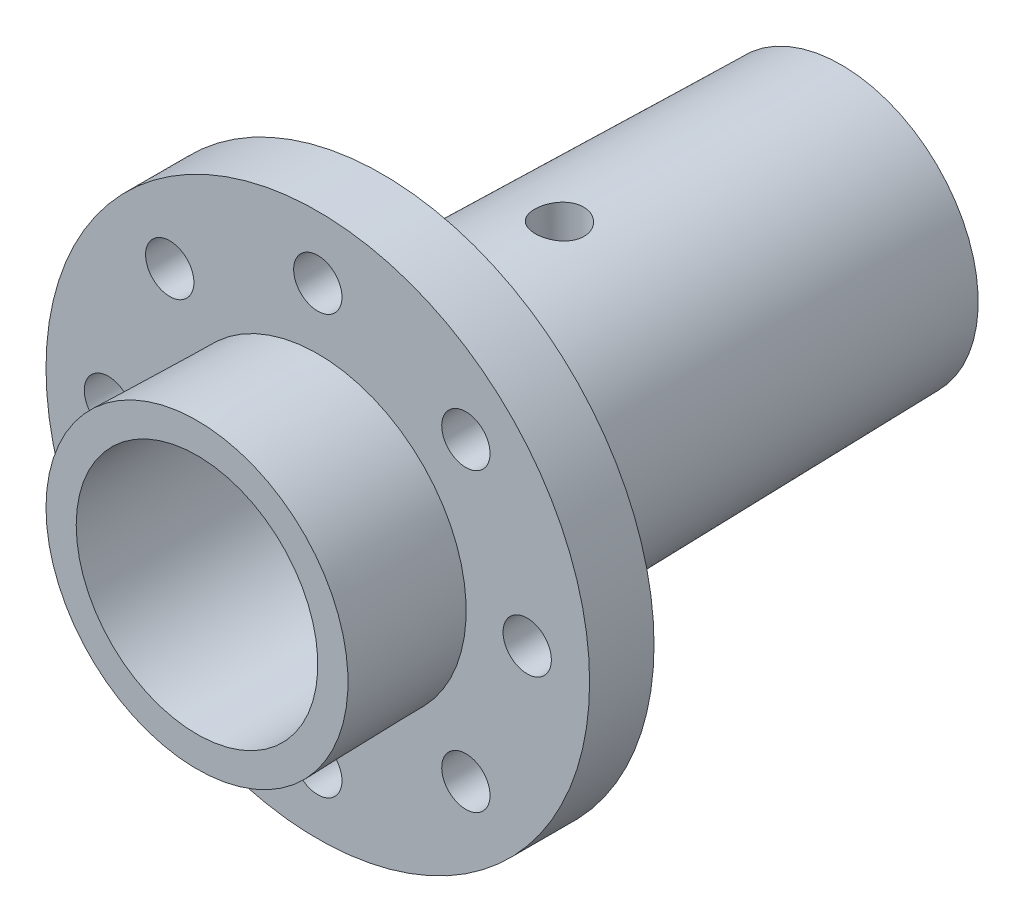
from build123d import *

# Parameters (mm, degrees)
SCHIZZO5_W                  = 15
SCHIZZO5_H                  = 30
SCHIZZO7_R                  = 3
TAGLIO_ESTRUSIONE1_DEPTH    = 24
RIPETIZIONECIRCOLARE1_COUNT = 8
SCHIZZO8_R                  = 3
TAGLIO_ESTRUSIONE2_DEPTH    = 34.75


with BuildPart() as part:
    # Schizzo3 → Rivoluzione2 (revolve)
    with BuildSketch(Plane(origin=(0, 0, 0), x_dir=(1, 0, 0), z_dir=(0, 1, 0))):
        Polygon((-17, 40), (-12, 40), (-12, -40), (-18.75, -40), (-18.421875, -25), (-33.75, -25), (-33.75, -17), (-18.246875, -17), align=None)
    revolve(axis=Axis((0, 0, -65.081098712), (0, 0, 1)))

    # Schizzo5 → Taglia-Rivoluzione1 (revolve, cut)
    with BuildSketch(Plane(origin=(0, 0, 0), x_dir=(1, 0, 0), z_dir=(0, 1, 0))):
        with Locations((-7.5, -25)):
            Rectangle(SCHIZZO5_W, SCHIZZO5_H)
    revolve(axis=Axis((0, 0, -67.558392607), (0, 0, 1)), mode=Mode.SUBTRACT)

    # Schizzo7 → Taglio-Estrusione1 (cut, through all)
    with BuildSketch(Plane(origin=(0, 0, 17), x_dir=(-1, 0, 0), z_dir=(0, 0, -1))):
        with Locations((0, -26)):
            Circle(SCHIZZO7_R)
    taglio_estrusione1 = extrude(amount=-TAGLIO_ESTRUSIONE1_DEPTH, mode=Mode.SUBTRACT)

    # RipetizioneCircolare1: Taglio-Estrusione1 ×8 about axis
    ripetizionecircolare1_axis = Axis((0, 0, 0), (0, 0, 1))
    for i in range(1, RIPETIZIONECIRCOLARE1_COUNT):
        add(taglio_estrusione1.rotate(ripetizionecircolare1_axis, i * 360 / RIPETIZIONECIRCOLARE1_COUNT), mode=Mode.SUBTRACT)

    # Schizzo8 → Taglio-Estrusione2 (cut, through all)
    with BuildSketch(Plane(origin=(0, 0, 0), x_dir=(1, 0, 0), z_dir=(0, 1, 0))):
        with Locations((0, 5)):
            Circle(SCHIZZO8_R)
    extrude(amount=TAGLIO_ESTRUSIONE2_DEPTH, mode=Mode.SUBTRACT)


solid = part.part
